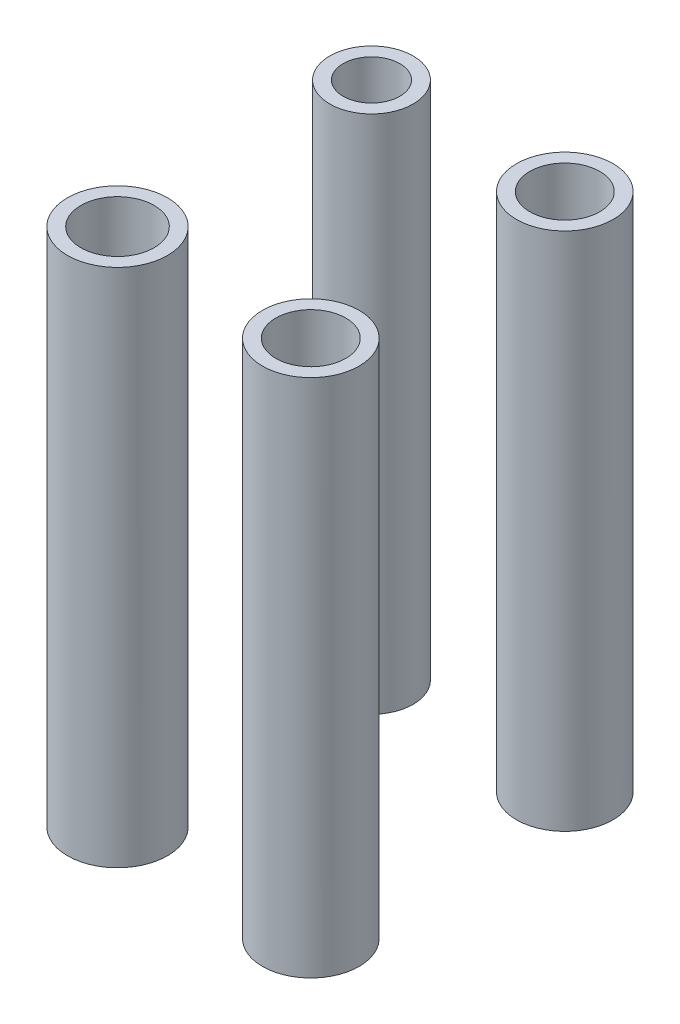
from build123d import *

# Parameters (mm, degrees)
CROQUIS1_W              = 49
CROQUIS1_H              = 73
CROQUIS1_R              = 5.25
CROQUIS1_R_2            = 5.5
CROQUIS1_R_3            = 4.25
CROQUIS1_R_4            = 3
SALIENTE_EXTRUIR4_DEPTH = 2
CROQUIS7_W              = 49
CROQUIS7_H              = 5
SALIENTE_EXTRUIR5_DEPTH = 2
CROQUIS8_R              = 3
CORTAR_EXTRUIR2_DEPTH   = 10
CROQUIS9_R              = 6.25
CROQUIS9_R_2            = 4.25
SALIENTE_EXTRUIR6_DEPTH = 80
CROQUIS10_R             = 7.25
CROQUIS10_R_2           = 5.25
SALIENTE_EXTRUIR7_DEPTH = 80
CROQUIS11_R             = 7.5
CROQUIS11_R_2           = 5.5
CROQUIS11_R_3           = 7.25
CROQUIS11_R_4           = 5.25
SALIENTE_EXTRUIR8_DEPTH = 80
CROQUIS12_W             = 49.867597571
CROQUIS12_H             = 5.700105039
CORTAR_EXTRUIR3_DEPTH   = 79


with BuildPart() as part:
    # Croquis1 → Saliente-Extruir4 (new body)
    with BuildSketch(Plane(origin=(0, 0, 0), x_dir=(1, 0, 0), z_dir=(0, 1, 0))):
        with Locations((0, 0.5)):
            Rectangle(CROQUIS1_W, CROQUIS1_H)
        with Locations((14.5, -21.1)):
            Circle(CROQUIS1_R, mode=Mode.SUBTRACT)
        with Locations((-14.5, -21.1)):
            Circle(CROQUIS1_R_2, mode=Mode.SUBTRACT)
        with Locations((-14.5, 17)):
            Circle(CROQUIS1_R_3, mode=Mode.SUBTRACT)
        with Locations((14.5, 17)):
            Circle(CROQUIS1_R, mode=Mode.SUBTRACT)
        with Locations((-19.5, 32)):
            Circle(CROQUIS1_R_4, mode=Mode.SUBTRACT)
        with Locations((19.5, 32)):
            Circle(CROQUIS1_R_4, mode=Mode.SUBTRACT)
    extrude(amount=SALIENTE_EXTRUIR4_DEPTH)

    # Croquis7 → Saliente-Extruir5 (add)
    with BuildSketch(Plane(origin=(0, 2, 0), x_dir=(1, 0, 0), z_dir=(0, 1, 0))):
        with Locations((0, -38.5)):
            Rectangle(CROQUIS7_W, CROQUIS7_H)
    extrude(amount=-SALIENTE_EXTRUIR5_DEPTH)

    # Croquis8 → Cortar-Extruir2 (cut)
    with BuildSketch(Plane(origin=(0, 2, 0), x_dir=(1, 0, 0), z_dir=(0, 1, 0))):
        with Locations((-19.5, -36)):
            Circle(CROQUIS8_R)
        with Locations((19.5, -36)):
            Circle(CROQUIS8_R)
    extrude(amount=-CORTAR_EXTRUIR2_DEPTH, mode=Mode.SUBTRACT)

    # Croquis9 → Saliente-Extruir6 (add)
    with BuildSketch(Plane(origin=(0, 2, 0), x_dir=(1, 0, 0), z_dir=(0, 1, 0))):
        with Locations((-14.5, 17)):
            Circle(CROQUIS9_R)
        with Locations((-14.5, 17)):
            Circle(CROQUIS9_R_2, mode=Mode.SUBTRACT)
    extrude(amount=-SALIENTE_EXTRUIR6_DEPTH)

    # Croquis10 → Saliente-Extruir7 (add)
    with BuildSketch(Plane(origin=(0, 2, 0), x_dir=(1, 0, 0), z_dir=(0, 1, 0))):
        with Locations((14.5, 17)):
            Circle(CROQUIS10_R)
        with Locations((14.5, 17)):
            Circle(CROQUIS10_R_2, mode=Mode.SUBTRACT)
    extrude(amount=-SALIENTE_EXTRUIR7_DEPTH)

    # Croquis11 → Saliente-Extruir8 (add)
    with BuildSketch(Plane(origin=(0, 2, 0), x_dir=(1, 0, 0), z_dir=(0, 1, 0))):
        with Locations((-14.5, -21.1)):
            Circle(CROQUIS11_R)
        with Locations((-14.5, -21.1)):
            Circle(CROQUIS11_R_2, mode=Mode.SUBTRACT)
        with Locations((14.5, -21.1)):
            Circle(CROQUIS11_R_3)
        with Locations((14.5, -21.1)):
            Circle(CROQUIS11_R_4, mode=Mode.SUBTRACT)
    extrude(amount=-SALIENTE_EXTRUIR8_DEPTH)

    # Croquis12 → Cortar-Extruir3 (cut, through all)
    with BuildSketch(Plane(origin=(0, 0, -37), x_dir=(-1, 0, 0), z_dir=(0, 0, -1))):
        with Locations((0.433798786, 2.85005252)):
            Rectangle(CROQUIS12_W, CROQUIS12_H)
    extrude(amount=-CORTAR_EXTRUIR3_DEPTH, mode=Mode.SUBTRACT)


solid = part.part
